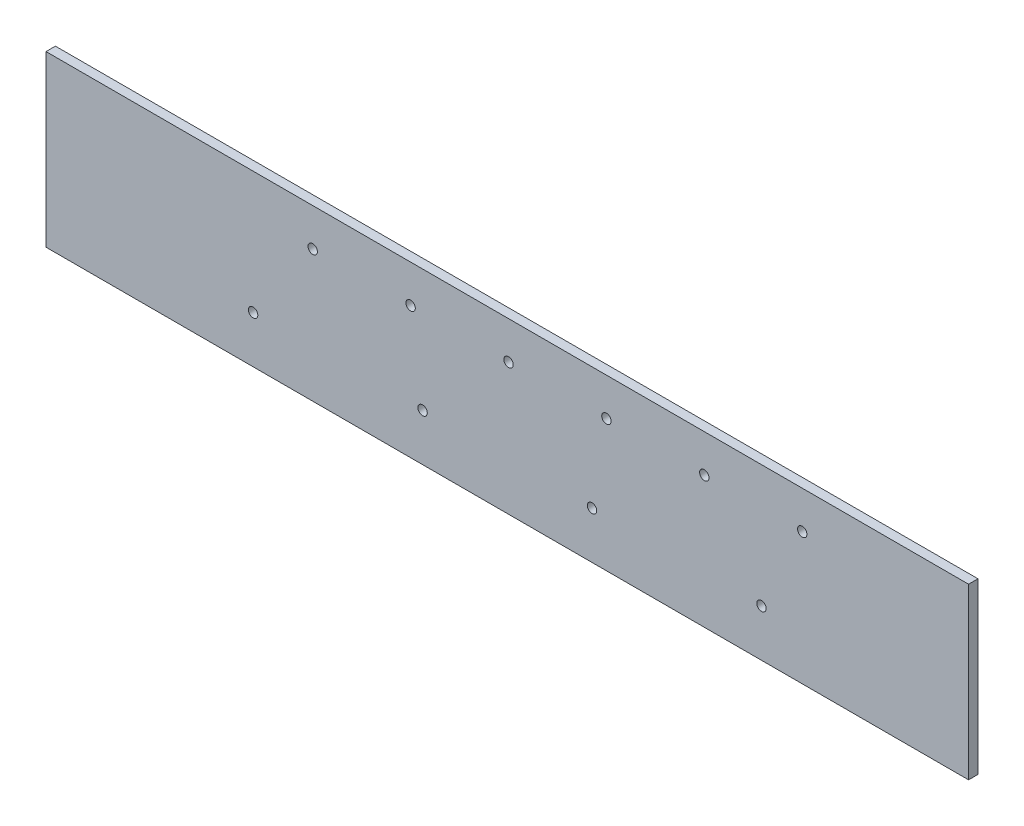
from build123d import *

# Parameters (mm, degrees)
SKETCH1_W                   = 622.3
SKETCH1_H                   = 114.3
BOSS_EXTRUDE1_DEPTH         = 6.35
F_1_4_0_25_DIAMETER_HOLE1_D = 6.35
LPATTERN1_COUNT             = 6
LPATTERN1_PITCH             = 66.04
F_1_4_0_25_DIAMETER_HOLE2_D = 6.35
LPATTERN2_COUNT             = 4
LPATTERN2_PITCH             = 114.3


with BuildPart() as part:
    # Sketch1 → Boss-Extrude1 (new body)
    with BuildSketch(Plane.XY.offset(457.2)):
        with Locations((0, 57.15)):
            Rectangle(SKETCH1_W, SKETCH1_H)
    extrude(amount=BOSS_EXTRUDE1_DEPTH)

    # 1/4 (0.25) Diameter Hole1 (through all)
    with Locations(Plane.XY.offset(463.55)):
        with Locations((-131.259730304, 88.9)):
            f_1_4_0_25_diameter_hole1 = Hole(F_1_4_0_25_DIAMETER_HOLE1_D / 2)

    # LPattern1: 1/4 (0.25) Diameter Hole1 ×6
    with Locations(*[(i * LPATTERN1_PITCH, 0, 0) for i in range(1, LPATTERN1_COUNT)]):
        add(f_1_4_0_25_diameter_hole1, mode=Mode.SUBTRACT)

    # 1/4 (0.25) Diameter Hole2 (through all)
    with Locations(Plane.XY.offset(463.55)):
        with Locations((-171.45, 31.75)):
            f_1_4_0_25_diameter_hole2 = Hole(F_1_4_0_25_DIAMETER_HOLE2_D / 2)

    # LPattern2: 1/4 (0.25) Diameter Hole2 ×4
    with Locations(*[(i * LPATTERN2_PITCH, 0, 0) for i in range(1, LPATTERN2_COUNT)]):
        add(f_1_4_0_25_diameter_hole2, mode=Mode.SUBTRACT)


solid = part.part
